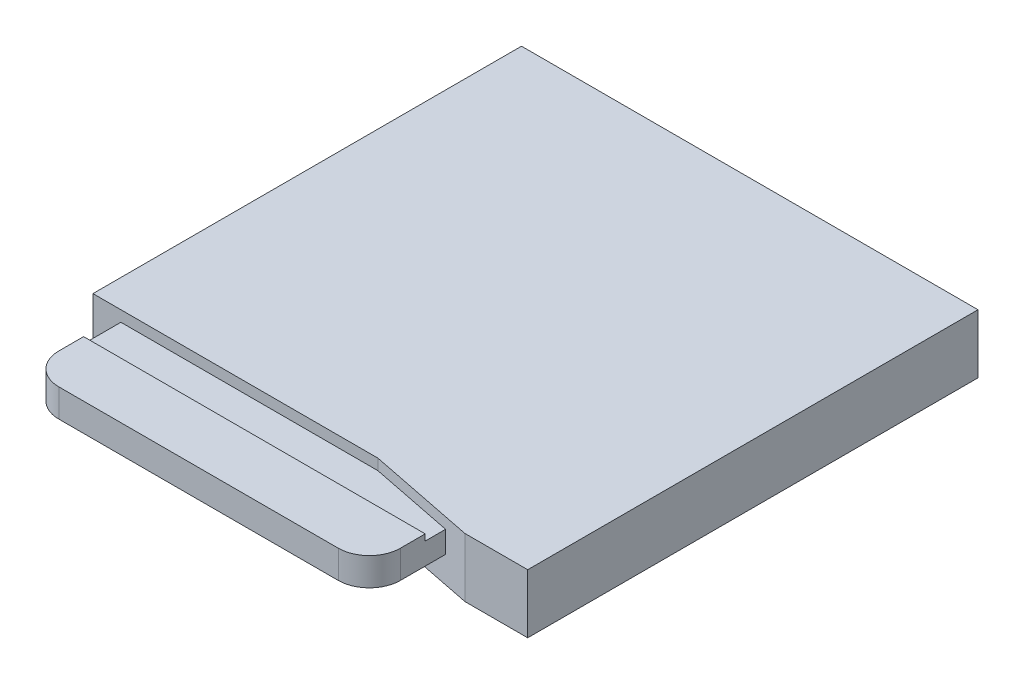
from build123d import *

# Parameters (mm, degrees)
SKETCH1_W               = 14.7
SKETCH1_H               = 14.5
BOSS_EXTRUDE1_DEPTH     = 1.9
CUT_EXTRUDE1_DEPTH      = 1
CUT_EXTRUDE1_DEPTH_BACK = 1.9
SKETCH3_W               = 11
SKETCH3_H               = 0.7
BOSS_EXTRUDE2_DEPTH     = 3
SKETCH4_W               = 11
SKETCH4_H               = 1.8
BOSS_EXTRUDE3_DEPTH     = 0.2
FILLET1_R               = 1
SKETCH5_R               = 0.4
BOSS_EXTRUDE4_DEPTH     = 0.55
FILLET2_R               = 0.1


with BuildPart() as part:
    # Sketch1 → Boss-Extrude1 (new body)
    with BuildSketch(Plane(origin=(0, 0, 0), x_dir=(1, 0, 0), z_dir=(0, 1, 0))):
        Rectangle(SKETCH1_W, SKETCH1_H)
    extrude(amount=BOSS_EXTRUDE1_DEPTH)

    # Sketch2 → Cut-Extrude1 (cut, two sides)
    with BuildSketch(Plane(origin=(0, 1.9, 0), x_dir=(1, 0, 0), z_dir=(0, 1, 0))) as cut_extrude1_sk:
        Polygon((-57.675178239, -6.55), (-7.35, -6.55), (1.824899914, -6.55), (5.328458875, -7.25), (54.6782833, -17.109938843), (45.259811524, -117.318654275), (-67.093650016, -106.758715432), align=None)
    extrude(amount=CUT_EXTRUDE1_DEPTH, mode=Mode.SUBTRACT)
    extrude(cut_extrude1_sk.sketch, amount=-CUT_EXTRUDE1_DEPTH_BACK, mode=Mode.SUBTRACT)

    # Sketch3 → Boss-Extrude2 (add)
    with BuildSketch(Plane.XY.offset(6.55)):
        with Locations((-0.95, 1.2)):
            Rectangle(SKETCH3_W, SKETCH3_H)
    extrude(amount=BOSS_EXTRUDE2_DEPTH)

    # Sketch4 → Boss-Extrude3 (add)
    with BuildSketch(Plane(origin=(0, 1.55, 0), x_dir=(1, 0, 0), z_dir=(0, 1, 0))):
        with Locations((-0.95, -8.65)):
            Rectangle(SKETCH4_W, SKETCH4_H)
    extrude(amount=BOSS_EXTRUDE3_DEPTH)

    # Fillet1
    fillet1_edges = [part.edges().sort_by_distance(p)[0] for p in [
        (-6.45, 1.3, 9.55),
        (4.55, 1.3, 9.55),
    ]]
    fillet(fillet1_edges, radius=FILLET1_R)

    # Sketch5 → Boss-Extrude4 (add)
    with BuildSketch(Plane.XZ):
        with Locations((-4.95, 3.25)):
            Circle(SKETCH5_R)
        with Locations((3.05, 3.25)):
            Circle(SKETCH5_R)
    extrude(amount=BOSS_EXTRUDE4_DEPTH)

    # Fillet2
    fillet2_edges = [part.edges().sort_by_distance(p)[0] for p in [
        (-5.35, -0.55, 3.25),
        (2.65, -0.55, 3.25),
    ]]
    fillet(fillet2_edges, radius=FILLET2_R)


solid = part.part
